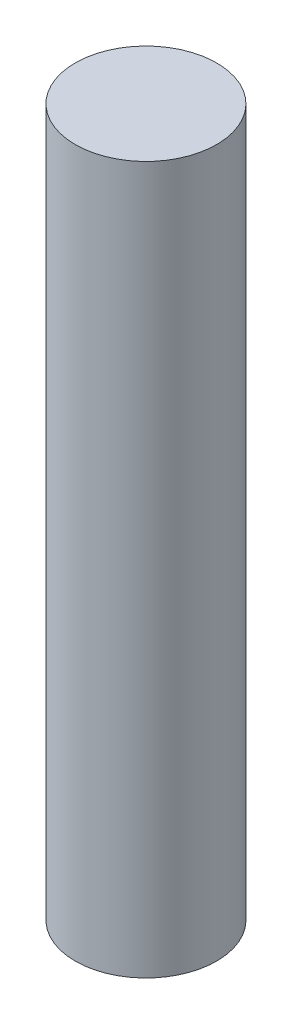
from build123d import *

# Parameters (mm, degrees)
SKETCH1_R           = 5.08
BOSS_EXTRUDE1_DEPTH = 50.8


with BuildPart() as part:
    # Sketch1 → Boss-Extrude1 (new body)
    with BuildSketch(Plane(origin=(0, 0, 0), x_dir=(1, 0, 0), z_dir=(0, 1, 0))):
        Circle(SKETCH1_R)
    extrude(amount=BOSS_EXTRUDE1_DEPTH)


solid = part.part
